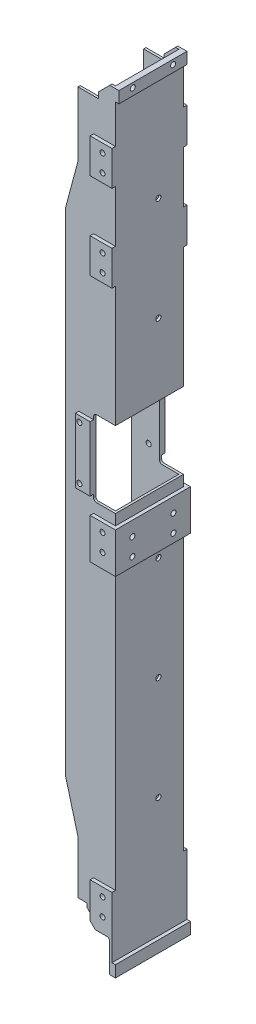
from build123d import *

# Parameters (mm, degrees)
EXTRUDE1_DEPTH                       = 32.5
SKETCH3_W                            = 60
SKETCH3_H                            = 55
CUT_EXTRUDE1_DEPTH                   = 48.5
CUT_EXTRUDE1_DEPTH_BACK              = 650.5
SKETCH4_W                            = 25.25
SKETCH4_H                            = 66
CUT_EXTRUDE2_DEPTH                   = 35
F_8_CLEARANCE_HOLE1_D                = 4.4958
LPATTERN1_COUNT                      = 7
LPATTERN1_PITCH                      = 90
TAPPED_HOLE_FOR_8_32_HELICOIL2_D     = 4.3942
TAPPED_HOLE_FOR_8_32_HELICOIL2_DEPTH = 11.1252
TAPPED_HOLE_FOR_8_32_HELICOIL2_TIP   = 1.320150866
TAPPED_HOLE_FOR_8_32_HELICOIL6_D     = 4.3942
TAPPED_HOLE_FOR_8_32_HELICOIL6_DEPTH = 11.1252
TAPPED_HOLE_FOR_8_32_HELICOIL6_TIP   = 1.320150866
TAPPED_HOLE_FOR_8_32_HELICOIL3_D     = 4.3942
TAPPED_HOLE_FOR_8_32_HELICOIL4_D     = 4.3942
SKETCH35_W                           = 83.352933337
SKETCH35_H                           = 26
SKETCH35_H_2                         = 10
EXTRUDE18_DEPTH                      = 206.779133429
TAPPED_HOLE_FOR_8_32_HELICOIL5_D     = 4.3942
CUT_EXTRUDE4_DEPTH                   = 66
CHAMFER1_SIZE                        = 10
SKETCH38_W                           = 17.65
SKETCH38_H                           = 15
CUT_EXTRUDE5_DEPTH                   = 66
CHAMFER2_SIZE                        = 10
CUT_EXTRUDE13_START                  = 32.5
SKETCH40_W                           = 12.75
SKETCH40_H                           = 56
CUT_EXTRUDE13_DEPTH                  = 3
CUT_EXTRUDE14_START                  = -32.5
SKETCH40_3_W                         = 12.75
SKETCH40_3_H                         = 56
CUT_EXTRUDE14_DEPTH                  = 3
SKETCH42_W                           = 91.864816585
SKETCH42_H                           = 689.904772547
SKETCH42_W_2                         = 59
SKETCH42_H_2                         = 10
SKETCH42_W_3                         = 65
SKETCH42_H_3                         = 35
CUT_EXTRUDE15_DEPTH                  = 3
FILLET2_R                            = 2.5


with BuildPart() as part:
    # Sketch2 → Extrude1 (new body, symmetric)
    with BuildSketch(Plane.XY):
        Polygon((170.229133429, 47.5), (170.229133429, -47.5), (159.529133429, -87.432943641), (159.529133429, -514.567056359), (170.229133429, -554.5), (170.229133429, -649.5), (205.779133429, -649.5), (205.779133429, 47.5), align=None)
    extrude(amount=EXTRUDE1_DEPTH, both=True)

    # Sketch3 → Cut-Extrude1 (cut, two sides)
    with BuildSketch(Plane(origin=(0, 0, 0), x_dir=(1, 0, 0), z_dir=(0, 1, 0))) as cut_extrude1_sk:
        with Locations((170.779133429, 0)):
            Rectangle(SKETCH3_W, SKETCH3_H)
    extrude(amount=CUT_EXTRUDE1_DEPTH, mode=Mode.SUBTRACT)
    extrude(cut_extrude1_sk.sketch, amount=-CUT_EXTRUDE1_DEPTH_BACK, mode=Mode.SUBTRACT)

    # Sketch4 → Cut-Extrude2 (cut, symmetric)
    with BuildSketch(Plane.XY):
        with Locations((196.404133429, -262.7)):
            Rectangle(SKETCH4_W, SKETCH4_H)
    extrude(amount=CUT_EXTRUDE2_DEPTH, both=True, mode=Mode.SUBTRACT)

    # 8 Clearance Hole1 (through all)
    with Locations(Plane(origin=(205.779133429, -77.5, -7.728), x_dir=(0, 1, 0), z_dir=(1, 0, 0))):
        with Locations((0, 0)):
            f_8_clearance_hole1 = Hole(F_8_CLEARANCE_HOLE1_D / 2)

    # LPattern1: 8 Clearance Hole1 ×7, 2 skipped
    with Locations(*[(0, -i * LPATTERN1_PITCH, 0) for i in range(1, LPATTERN1_COUNT) if i not in (2, 6)]):
        add(f_8_clearance_hole1, mode=Mode.SUBTRACT)

    # Tapped Hole for _8-32 Helicoil2
    with Locations(Plane(origin=(194.579133429, -27.5, 32.5), x_dir=(1, 0, 0), z_dir=(0, 0, 1))):
        with Locations((0, 0), (0, -15), (0, -75), (0, -90), (0, -285), (0, -300), (0, -558.7), (0, -573.7)):
            Hole(TAPPED_HOLE_FOR_8_32_HELICOIL2_D / 2, depth=TAPPED_HOLE_FOR_8_32_HELICOIL2_DEPTH)
            with Locations((0, 0, -(TAPPED_HOLE_FOR_8_32_HELICOIL2_DEPTH + TAPPED_HOLE_FOR_8_32_HELICOIL2_TIP / 2))):  # 118° drill point
                Cone(0, TAPPED_HOLE_FOR_8_32_HELICOIL2_D / 2, TAPPED_HOLE_FOR_8_32_HELICOIL2_TIP, mode=Mode.SUBTRACT)

    # Tapped Hole for _8-32 Helicoil6
    with Locations(Plane(origin=(0, 0, -32.5), x_dir=(-1, 0, 0), z_dir=(0, 0, -1))):
        with Locations((-194.579133429, -27.5), (-194.579133429, -42.5), (-194.579133429, -102.5), (-194.579133429, -117.5), (-194.579133429, -312.5), (-194.579133429, -327.5), (-194.579133429, -586.2), (-194.579133429, -601.2)):
            Hole(TAPPED_HOLE_FOR_8_32_HELICOIL6_D / 2, depth=TAPPED_HOLE_FOR_8_32_HELICOIL6_DEPTH)
            with Locations((0, 0, -(TAPPED_HOLE_FOR_8_32_HELICOIL6_DEPTH + TAPPED_HOLE_FOR_8_32_HELICOIL6_TIP / 2))):  # 118° drill point
                Cone(0, TAPPED_HOLE_FOR_8_32_HELICOIL6_D / 2, TAPPED_HOLE_FOR_8_32_HELICOIL6_TIP, mode=Mode.SUBTRACT)

    # Tapped Hole for _8-32 Helicoil3 (through all)
    with Locations(Plane(origin=(205.779133429, 0, 0), x_dir=(0, 0, -1), z_dir=(1, 0, 0))):
        with Locations((-17.8, -317.5), (17.8, -317.5), (-17.8, -332.5), (17.8, -332.5)):
            Hole(TAPPED_HOLE_FOR_8_32_HELICOIL3_D / 2)

    # Tapped Hole for _8-32 Helicoil4 (through all)
    with Locations(Plane(origin=(174.529133429, -239.7, 32.5), x_dir=(1, 0, 0), z_dir=(0, 0, 1))):
        with Locations((0, 0), (0, -46)):
            Hole(TAPPED_HOLE_FOR_8_32_HELICOIL4_D / 2)

    # Sketch35 → Extrude18 (cut, through all)
    with BuildSketch(Plane(origin=(0, 0, 0), x_dir=(0, 0, -1), z_dir=(1, 0, 0))):
        with Locations((-1.322638192, 36.5)):
            Rectangle(SKETCH35_W, SKETCH35_H)
        with Locations((-1.322638192, -646.5)):
            Rectangle(SKETCH35_W, SKETCH35_H_2)
    extrude(amount=EXTRUDE18_DEPTH, mode=Mode.SUBTRACT)

    # Tapped Hole for _8-32 Helicoil5 (through all)
    with Locations(Plane(origin=(205.779133429, 19.5, 17.5), x_dir=(0, 1, 0), z_dir=(1, 0, 0))):
        with Locations((0, 0), (0, -35)):
            Hole(TAPPED_HOLE_FOR_8_32_HELICOIL5_D / 2)

    # Sketch37 → Cut-Extrude4 (cut, through all)
    with BuildSketch(Plane(origin=(0, 0, -32.5), x_dir=(-1, 0, 0), z_dir=(0, 0, -1))):
        Polygon((-200.779133429, -641.5), (-170.229133429, -641.5), (-170.229133429, -609.356521994), (-170.229133429, -600.5), (-178.279133429, -600.5), (-178.279133429, -614), (-200.779133429, -614), align=None)
    extrude(amount=-CUT_EXTRUDE4_DEPTH, mode=Mode.SUBTRACT)

    # Chamfer1
    chamfer1_edges = [part.edges().sort_by_distance(p)[0] for p in [
        (178.279133429, -614, -30),
        (178.279133429, -614, 30),
    ]]
    chamfer(chamfer1_edges, length=CHAMFER1_SIZE)

    # Sketch38 → Cut-Extrude5 (cut, through all)
    with BuildSketch(Plane.XY.offset(32.5)):
        with Locations((179.054133429, 16)):
            Rectangle(SKETCH38_W, SKETCH38_H)
    extrude(amount=-CUT_EXTRUDE5_DEPTH, mode=Mode.SUBTRACT)

    # Chamfer2
    chamfer2_edges = [part.edges().sort_by_distance(p)[0] for p in [
        (187.879133429, 23.5, 30),
        (187.879133429, 23.5, -30),
    ]]
    chamfer(chamfer2_edges, length=CHAMFER2_SIZE)

    # Sketch40 → Cut-Extrude13 (cut)
    with BuildSketch(Plane.XY.offset(CUT_EXTRUDE13_START)):
        Polygon((134.931335664, 87.372466397), (210.779133429, 87.372466397), (210.779133429, -20), (183.779133429, -20), (183.779133429, -50), (210.779133429, -50), (210.779133429, -95), (183.779133429, -95), (183.779133429, -125), (210.779133429, -125), (210.779133429, -305), (183.779133429, -305), (183.779133429, -340), (210.779133429, -340), (210.779133429, -578.7), (183.779133429, -578.7), (183.779133429, -616.252685753), (134.931335664, -616.252685753), align=None)
        with Locations((177.404133429, -262.7)):
            Rectangle(SKETCH40_W, SKETCH40_H, mode=Mode.SUBTRACT)
    extrude(amount=-CUT_EXTRUDE13_DEPTH, mode=Mode.SUBTRACT)

    # Sketch40_3 → Cut-Extrude14 (cut)
    with BuildSketch(Plane.XY.offset(CUT_EXTRUDE14_START)):
        Polygon((134.931335664, 87.372466397), (210.779133429, 87.372466397), (210.779133429, -20), (183.779133429, -20), (183.779133429, -50), (210.779133429, -50), (210.779133429, -95), (183.779133429, -95), (183.779133429, -125), (210.779133429, -125), (210.779133429, -305), (183.779133429, -305), (183.779133429, -340), (210.779133429, -340), (210.779133429, -578.7), (183.779133429, -578.7), (183.779133429, -616.252685753), (134.931335664, -616.252685753), align=None)
        with Locations((177.404133429, -262.7)):
            Rectangle(SKETCH40_3_W, SKETCH40_3_H, mode=Mode.SUBTRACT)
    extrude(amount=CUT_EXTRUDE14_DEPTH, mode=Mode.SUBTRACT)

    # Sketch42 → Cut-Extrude15 (cut)
    with BuildSketch(Plane(origin=(205.779133429, 0, 0), x_dir=(0, 0, -1), z_dir=(1, 0, 0))):
        with Locations((-0.915268581, -304.741083254)):
            Rectangle(SKETCH42_W, SKETCH42_H)
        with Locations((0, 18.5)):
            Rectangle(SKETCH42_W_2, SKETCH42_H_2, mode=Mode.SUBTRACT)
        with Locations((0, -322.5)):
            Rectangle(SKETCH42_W_3, SKETCH42_H_3, mode=Mode.SUBTRACT)
        with Locations((0, -636.5)):
            Rectangle(SKETCH42_W_3, SKETCH42_H_2, mode=Mode.SUBTRACT)
    extrude(amount=-CUT_EXTRUDE15_DEPTH, mode=Mode.SUBTRACT)

    # Fillet2
    fillet2_edges = [part.edges().sort_by_distance(p)[0] for p in [
        (200.779133429, -614, -30),
        (200.779133429, -614, 30),
        (183.779133429, -229.7, -28.5),
        (183.779133429, -295.7, -28.5),
        (183.779133429, -295.7, 28.5),
        (183.779133429, -229.7, 28.5),
    ]]
    fillet(fillet2_edges, radius=FILLET2_R)


solid = part.part
